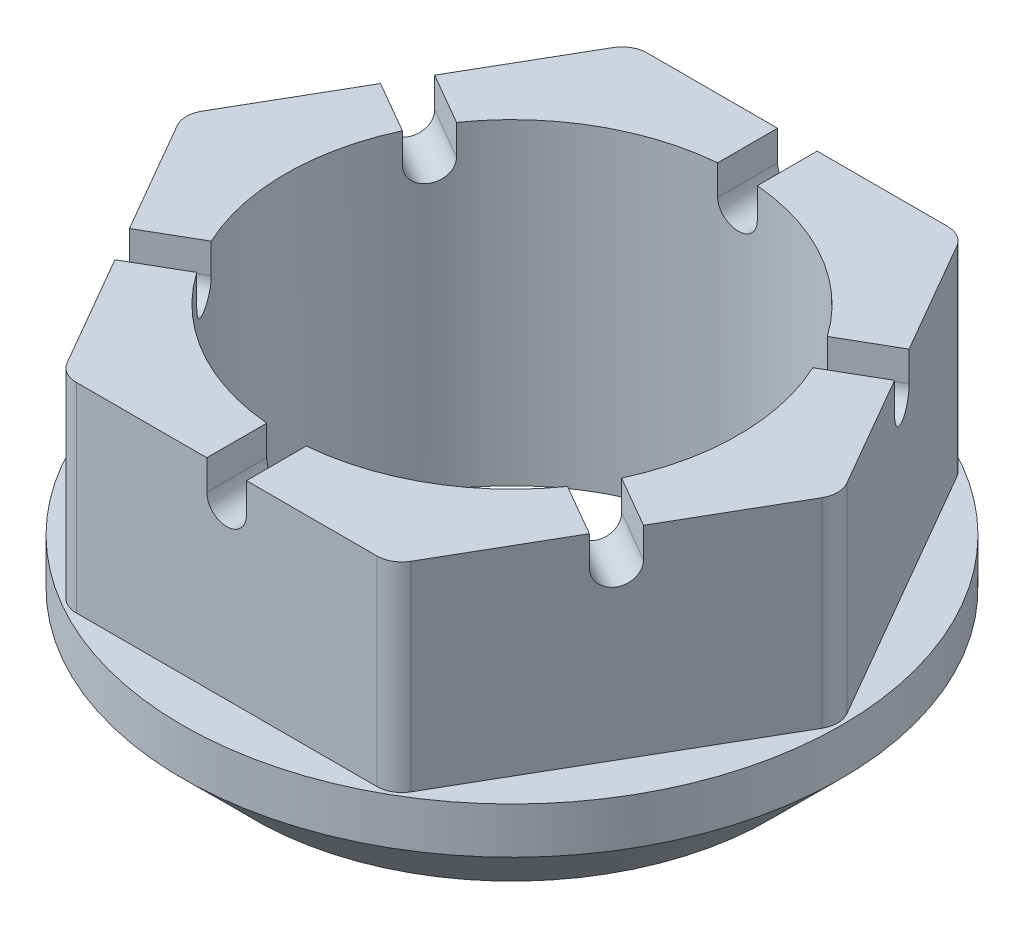
from build123d import *

# Parameters (mm, degrees)
CUT_EXTRUDE5_DEPTH = 20
FILLET4_R          = 2.5
CUT_EXTRUDE6_START = -62.5788381
CUT_EXTRUDE6_DEPTH = 96.5788382
CIRPATTERN2_COUNT  = 6


with BuildPart() as part:
    # Sketch1 → Revolve1 (revolve)
    with BuildSketch(Plane(origin=(0, 0, 0), x_dir=(0, 0, -1), z_dir=(1, 0, 0))):
        Polygon((-22.6695, -31.75), (-22.6695, 0), (-33, 0), (-33, -24.619433914), (-25.8445, -31.75), align=None)
    revolve(axis=Axis((0, 0, 0), (0, 1, 0)))

    # Sketch4 → Cut-Extrude5 (cut)
    with BuildSketch(Plane(origin=(0, 0, 0), x_dir=(1, 0, 0), z_dir=(0, 1, 0))):
        with BuildLine():
            ThreePointArc((33, 0), (28.578838325, 16.5), (16.5, 28.578838325))
            Line((16.5, 28.578838325), (33, 0))
        make_face()
        with BuildLine():
            Line((-16.5, 28.578838325), (16.5, 28.578838325))
            ThreePointArc((16.5, 28.578838325), (0, 33), (-16.5, 28.578838325))
        make_face()
        with BuildLine():
            Line((-33, 0), (-16.5, 28.578838325))
            ThreePointArc((-16.5, 28.578838325), (-28.578838325, 16.5), (-33, 0))
        make_face()
        with BuildLine():
            ThreePointArc((16.5, -28.578838325), (28.578838325, -16.5), (33, 0))
            Line((33, 0), (16.5, -28.578838325))
        make_face()
        with BuildLine():
            Line((-16.5, -28.578838325), (-33, 0))
            ThreePointArc((-33, 0), (-28.578838325, -16.5), (-16.5, -28.578838325))
        make_face()
        with BuildLine():
            ThreePointArc((-16.5, -28.578838325), (0, -33), (16.5, -28.578838325))
            Line((16.5, -28.578838325), (-16.5, -28.578838325))
        make_face()
    extrude(amount=-CUT_EXTRUDE5_DEPTH, mode=Mode.SUBTRACT)

    # Fillet4
    fillet4_edges = [part.edges().sort_by_distance(p)[0] for p in [
        (33, -10, 0),
        (16.5, -10, -28.578838325),
        (-33, -10, 0),
        (16.5, -10, 28.578838325),
        (-16.5, -10, -28.578838325),
        (-16.5, -10, 28.578838325),
    ]]
    fillet(fillet4_edges, radius=FILLET4_R)

    # Sketch7 → Cut-Extrude6 (cut)
    with BuildSketch(Plane.XY.offset(CUT_EXTRUDE6_START)):
        with BuildLine():
            Line((-1.984375, -3), (-1.984375, 0))
            Line((-1.984375, 0), (1.984375, 0))
            Line((1.984375, 0), (1.984375, -3))
            ThreePointArc((1.984375, -3), (0, -4.984375), (-1.984375, -3))
        make_face()
    cut_extrude6 = extrude(amount=CUT_EXTRUDE6_DEPTH, mode=Mode.SUBTRACT)

    # CirPattern2: Cut-Extrude6 ×6 about axis
    cirpattern2_axis = Axis((0, 0, 0), (0, 1, 0))
    for i in range(1, CIRPATTERN2_COUNT):
        add(cut_extrude6.rotate(cirpattern2_axis, i * 360 / CIRPATTERN2_COUNT), mode=Mode.SUBTRACT)


solid = part.part
